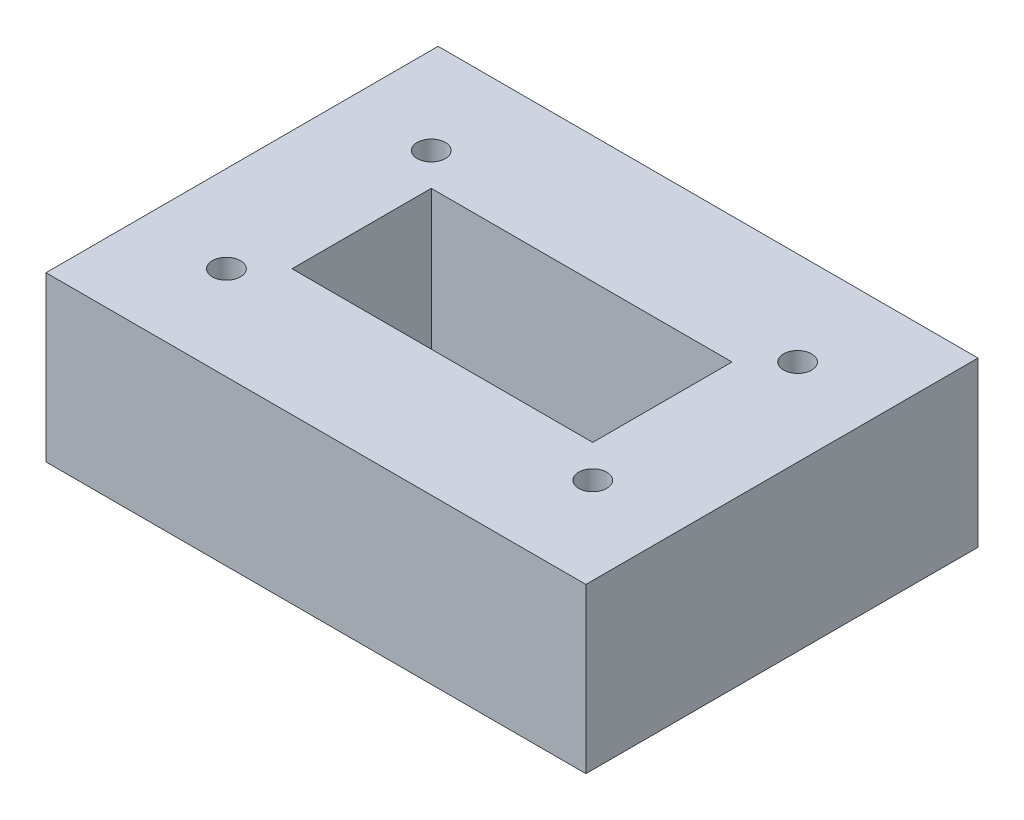
from build123d import *

# Parameters (mm, degrees)
SKETCH8_W           = 131.76
SKETCH8_H           = 95.69
SKETCH8_R           = 3.43
SKETCH8_W_2         = 73.4
SKETCH8_H_2         = 33.99
BOSS_EXTRUDE4_DEPTH = 40
SKETCH9_R           = 8
CUT_EXTRUDE2_DEPTH  = 8


with BuildPart() as part:
    # Sketch8 → Boss-Extrude4 (new body)
    with BuildSketch(Plane(origin=(0, 0, 0), x_dir=(1, 0, 0), z_dir=(0, 1, 0))):
        with Locations((-55.88, 37.845)):
            Rectangle(SKETCH8_W, SKETCH8_H)
        with Locations((-100.58, 12.85)):
            Circle(SKETCH8_R, mode=Mode.SUBTRACT)
        with Locations((-100.58, 62.84)):
            Circle(SKETCH8_R, mode=Mode.SUBTRACT)
        with Locations((-11.18, 62.84)):
            Circle(SKETCH8_R, mode=Mode.SUBTRACT)
        with Locations((-11.18, 12.85)):
            Circle(SKETCH8_R, mode=Mode.SUBTRACT)
        with Locations((-55.88, 37.845)):
            Rectangle(SKETCH8_W_2, SKETCH8_H_2, mode=Mode.SUBTRACT)
    extrude(amount=BOSS_EXTRUDE4_DEPTH)

    # Sketch9 → Cut-Extrude2 (cut)
    with BuildSketch(Plane.XZ):
        with Locations((-100.58, -12.85)):
            Circle(SKETCH9_R)
        with Locations((-11.18, -12.85)):
            Circle(SKETCH9_R)
        with Locations((-11.18, -62.84)):
            Circle(SKETCH9_R)
        with Locations((-100.58, -62.84)):
            Circle(SKETCH9_R)
    extrude(amount=-CUT_EXTRUDE2_DEPTH, mode=Mode.SUBTRACT)


solid = part.part
